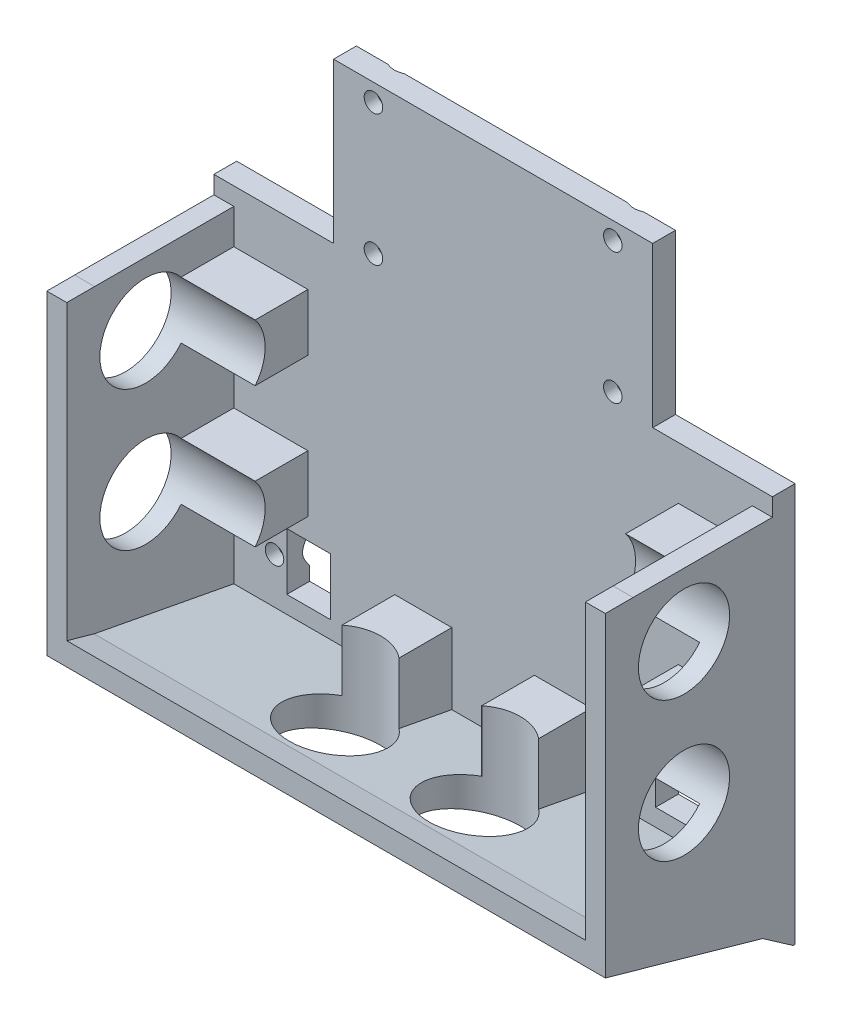
from build123d import *

# Parameters (mm, degrees)
CROQUIS1_R               = 1.625
SALIENTE_EXTRUIR1_DEPTH  = 4
SALIENTE_EXTRUIR2_DEPTH  = 3.5
CORTAR_EXTRUIR1_START    = -98
CORTAR_EXTRUIR1_DEPTH    = 98
SALIENTE_EXTRUIR4_DEPTH  = 3.5
CROQUIS11_W              = 3.5
CROQUIS11_H              = 24.500023525
SALIENTE_EXTRUIR16_DEPTH = 43.75
CORTAR_EXTRUIR2_START    = -98
CROQUIS13_R              = 8
CORTAR_EXTRUIR2_DEPTH    = 98
SALIENTE_EXTRUIR17_DEPTH = 91
CROQUIS15_R              = 8
CORTAR_EXTRUIR3_DEPTH    = 70
SALIENTE_EXTRUIR18_DEPTH = 98
SALIENTE_EXTRUIR19_START = -3.5
SALIENTE_EXTRUIR19_DEPTH = 3.5
SALIENTE_EXTRUIR20_START = -3.5
SALIENTE_EXTRUIR20_DEPTH = 3.5
CROQUIS22_R              = 1.625
CROQUIS22_W              = 7.7
CROQUIS22_H              = 10
CORTAR_EXTRUIR4_DEPTH    = 4
SALIENTE_EXTRUIR21_DEPTH = 13
SALIENTE_EXTRUIR22_DEPTH = 13
SALIENTE_EXTRUIR23_DEPTH = 9.25
CORTAR_EXTRUIR5_START    = -12.474615
CORTAR_EXTRUIR5_DEPTH    = 12.474615
CROQUIS27_R              = 3.36
CORTAR_EXTRUIR6_DEPTH    = 1.8
CORTAR_EXTRUIR6_TAPER    = 44


with BuildPart() as part:
    # Croquis1 → Saliente-Extruir1 (new body)
    with BuildSketch(Plane.XY):
        Polygon((99, -28), (99, -98), (1, -98), (1, -28), (22, -28), (22, 0), (78, 0), (78, -28), align=None)
        with Locations((29, -3.05)):
            Circle(CROQUIS1_R, mode=Mode.SUBTRACT)
        with Locations((29, -26.05)):
            Circle(CROQUIS1_R, mode=Mode.SUBTRACT)
        with Locations((71, -26.05)):
            Circle(CROQUIS1_R, mode=Mode.SUBTRACT)
        with Locations((71, -3.05)):
            Circle(CROQUIS1_R, mode=Mode.SUBTRACT)
    extrude(amount=SALIENTE_EXTRUIR1_DEPTH)

    # Croquis3 → Saliente-Extruir2 (add)
    with BuildSketch(Plane.ZY.offset(-1)):
        Polygon((4, -74.869484932), (3.981861285, -95.48724368), (5.706893625, -94.286253678), (28.5, -87.835533437), (28.5, -74.835533437), align=None)
    extrude(amount=-SALIENTE_EXTRUIR2_DEPTH)

    # Croquis4 → Cortar-Extruir1 (cut)
    with BuildSketch(Plane.ZY.offset(-1).offset(CORTAR_EXTRUIR1_START)):
        Polygon((4, -98), (0.372683932, -98), (4, -95.47461527), align=None)
    extrude(amount=CORTAR_EXTRUIR1_DEPTH, mode=Mode.SUBTRACT)

    # Croquis6 → Saliente-Extruir4 (add)
    with BuildSketch(Plane(origin=(99, 0, 0), x_dir=(0, 0, -1), z_dir=(1, 0, 0))):
        Polygon((-4, -95.47461527), (-5.706893625, -94.286253678), (-28.5, -87.835533437), (-28.5, -74.835533437), (-4, -74.869484932), align=None)
    extrude(amount=-SALIENTE_EXTRUIR4_DEPTH)

    # Croquis11 → Saliente-Extruir16 (add)
    with BuildSketch(Plane(origin=(0, -74.874884245, 0.103759765), x_dir=(1, 0, 0), z_dir=(0, 0.99999904, -0.001385774))):
        with Locations((97.25, -16.146255738)):
            Rectangle(CROQUIS11_W, CROQUIS11_H)
        with Locations((2.75, -16.146255738)):
            Rectangle(CROQUIS11_W, CROQUIS11_H)
    extrude(amount=SALIENTE_EXTRUIR16_DEPTH)

    # Croquis13 → Cortar-Extruir2 (cut)
    with BuildSketch(Plane.ZY.offset(-1).offset(CORTAR_EXTRUIR2_START)):
        with Locations((19.5, -42.25)):
            Circle(CROQUIS13_R)
        with Locations((19.5, -66.75)):
            Circle(CROQUIS13_R)
    extrude(amount=CORTAR_EXTRUIR2_DEPTH, mode=Mode.SUBTRACT)

    # Croquis14 → Saliente-Extruir17 (add)
    with BuildSketch(Plane.ZY.offset(-95.5)):
        Polygon((28.5, -87.835533437), (5.706893625, -94.286253678), (4, -95.47461527), (4, -88.47461527), (28.5, -83.835533437), align=None)
    extrude(amount=SALIENTE_EXTRUIR17_DEPTH)

    # Croquis15 → Cortar-Extruir3 (cut)
    with BuildSketch(Plane.XZ.offset(98)):
        with Locations((37.75, 19.5)):
            Circle(CROQUIS15_R)
        with Locations((62.25, 19.5)):
            Circle(CROQUIS15_R)
    extrude(amount=-CORTAR_EXTRUIR3_DEPTH, mode=Mode.SUBTRACT)

    # Croquis18 → Saliente-Extruir18 (add)
    with BuildSketch(Plane(origin=(99, 0, 0), x_dir=(0, 0, -1), z_dir=(1, 0, 0))):
        Polygon((-28.5, -87.835533437), (-33.311039019, -86.473952165), (-33.311039019, -82.473952165), (-28.5, -83.835533437), align=None)
    extrude(amount=-SALIENTE_EXTRUIR18_DEPTH)

    # Croquis19 → Saliente-Extruir19 (add)
    with BuildSketch(Plane(origin=(99, 0, 0), x_dir=(0, 0, -1), z_dir=(1, 0, 0)).offset(SALIENTE_EXTRUIR19_START)):
        Polygon((-28.5, -83.835533437), (-33.311039019, -82.473952165), (-33.311039019, -31.085575445), (-28.439372389, -31.085575445), (-28.5, -74.835533437), align=None)
    extrude(amount=SALIENTE_EXTRUIR19_DEPTH)

    # Croquis20 → Saliente-Extruir20 (add)
    with BuildSketch(Plane.ZY.offset(-1).offset(SALIENTE_EXTRUIR20_START)):
        Polygon((28.439372389, -31.085575445), (33.311039019, -31.085575445), (33.311039019, -82.473952165), (28.5, -83.835533437), (28.5, -74.835533437), align=None)
    extrude(amount=SALIENTE_EXTRUIR20_DEPTH)

    # Croquis22 → Cortar-Extruir4 (cut)
    with BuildSketch(Plane.XY.offset(4)):
        with Locations((88.362832, -80.438630677)):
            Circle(CROQUIS22_R)
        with Locations((11.637168, -80.438630677)):
            Circle(CROQUIS22_R)
        with Locations((82.35, -80.438630677)):
            Rectangle(CROQUIS22_W, CROQUIS22_H)
        with Locations((17.65, -80.438630677)):
            Rectangle(CROQUIS22_W, CROQUIS22_H)
    extrude(amount=-CORTAR_EXTRUIR4_DEPTH, mode=Mode.SUBTRACT)

    # Croquis23 → Saliente-Extruir21 (add)
    with BuildSketch(Plane(origin=(4.5, 0, 0), x_dir=(0, 0, -1), z_dir=(1, 0, 0))):
        with BuildLine():
            Line((-13.255002002, -71.75), (-4, -71.75))
            Line((-4, -71.75), (-4, -61.75))
            Line((-4, -61.75), (-13.255002002, -61.75))
            ThreePointArc((-13.255002002, -61.75), (-11.5, -66.75), (-13.255002002, -71.75))
        make_face()
        with BuildLine():
            Line((-4, -47.25), (-13.255002002, -47.25))
            ThreePointArc((-13.255002002, -47.25), (-11.5, -42.25), (-13.255002002, -37.25))
            Line((-13.255002002, -37.25), (-4, -37.25))
            Line((-4, -37.25), (-4, -47.25))
        make_face()
    extrude(amount=SALIENTE_EXTRUIR21_DEPTH)

    # Croquis24 → Saliente-Extruir22 (add)
    with BuildSketch(Plane.ZY.offset(-95.5)):
        with BuildLine():
            Line((13.255002002, -37.25), (4, -37.25))
            Line((4, -37.25), (4, -47.25))
            Line((4, -47.25), (13.255002002, -47.25))
            ThreePointArc((13.255002002, -47.25), (11.5, -42.25), (13.255002002, -37.25))
        make_face()
        with BuildLine():
            Line((13.255002002, -61.75), (4, -61.75))
            Line((4, -61.75), (4, -71.75))
            Line((4, -71.75), (13.255002002, -71.75))
            ThreePointArc((13.255002002, -71.75), (11.5, -66.75), (13.255002002, -61.75))
        make_face()
    extrude(amount=SALIENTE_EXTRUIR22_DEPTH)

    # Croquis25 → Saliente-Extruir23 (add)
    with BuildSketch(Plane.XY.offset(4)):
        Polygon((37.75, -88.47461527), (42.75, -88.47461527), (42.75, -76), (32.75, -76), (32.75, -88.47461527), align=None)
        Polygon((62.25, -88.47461527), (67.25, -88.47461527), (67.25, -76), (57.25, -76), (57.25, -88.47461527), align=None)
    extrude(amount=SALIENTE_EXTRUIR23_DEPTH)

    # Croquis26 → Cortar-Extruir5 (cut)
    with BuildSketch(Plane.XZ.offset(88.47461527).offset(CORTAR_EXTRUIR5_START)):
        with BuildLine():
            Line((57.256253911, 13.25), (67.243746089, 13.25))
            ThreePointArc((67.243746089, 13.25), (62.25, 11.5), (57.256253911, 13.25))
        make_face()
        with BuildLine():
            Line((32.756253911, 13.25), (42.743746089, 13.25))
            ThreePointArc((42.743746089, 13.25), (37.75, 11.5), (32.756253911, 13.25))
        make_face()
    extrude(amount=CORTAR_EXTRUIR5_DEPTH, mode=Mode.SUBTRACT)

    # Croquis27 → Cortar-Extruir6 (cut)
    with BuildSketch(Plane(origin=(0, 0, 0), x_dir=(-1, 0, 0), z_dir=(0, 0, -1))):
        with Locations((-29, -26.05)):
            Circle(CROQUIS27_R)
        with Locations((-71, -26.05)):
            Circle(CROQUIS27_R)
        with Locations((-71, -3.05)):
            Circle(CROQUIS27_R)
        with Locations((-29, -3.05)):
            Circle(CROQUIS27_R)
        with Locations((-11.637168, -80.438630677)):
            Circle(CROQUIS27_R)
        with Locations((-88.362832, -80.438630677)):
            Circle(CROQUIS27_R)
    extrude(amount=-CORTAR_EXTRUIR6_DEPTH, taper=CORTAR_EXTRUIR6_TAPER, mode=Mode.SUBTRACT)


solid = part.part
